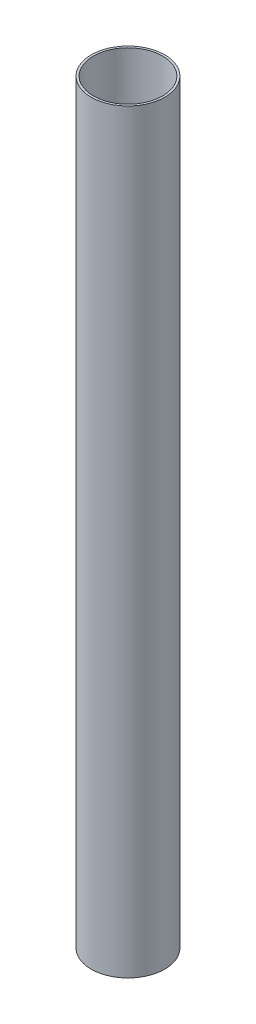
from build123d import *

# Parameters (mm, degrees)
SKETCH1_R      = 45.5803
SKETCH1_R_2    = 42.926
EXTRUDE1_DEPTH = 936.625


with BuildPart() as part:
    # Sketch1 → Extrude1 (new body)
    with BuildSketch(Plane(origin=(0, 0, 0), x_dir=(1, 0, 0), z_dir=(0, 1, 0))):
        Circle(SKETCH1_R)
        Circle(SKETCH1_R_2, mode=Mode.SUBTRACT)
    extrude(amount=EXTRUDE1_DEPTH)


solid = part.part
